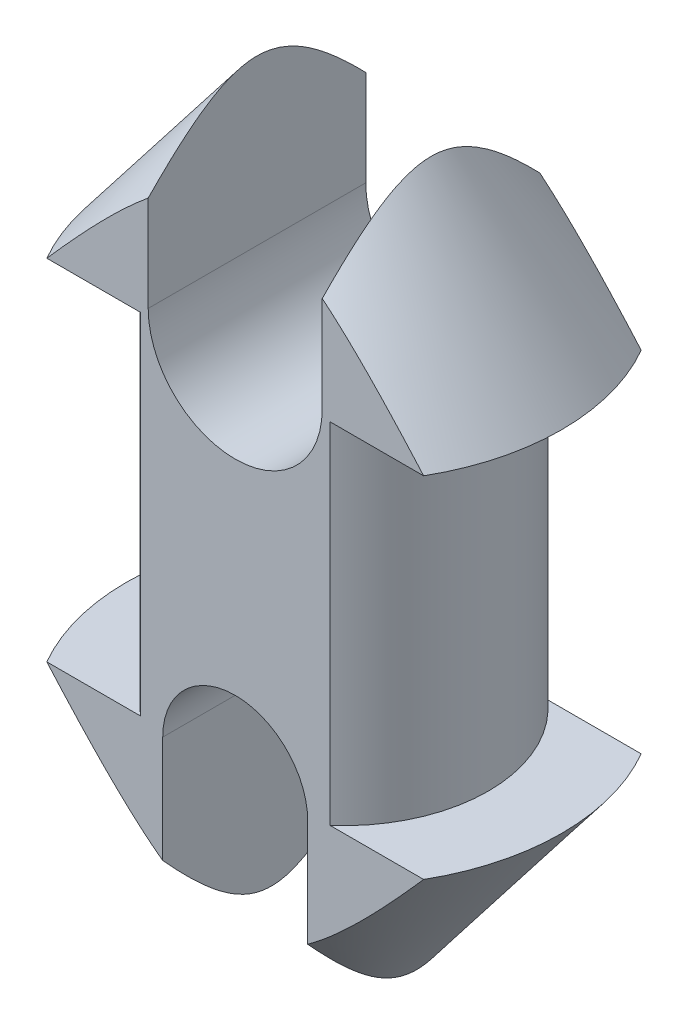
from build123d import *

# Parameters (mm, degrees)
ESBO_O2_OUTSIDE_W          = 45.75
ESBO_O2_OUTSIDE_H          = 45.75
ESBO_O2_OUTSIDE_W_2        = 30
ESBO_O2_OUTSIDE_H_2        = 15
CORTE_EXTRUS_O1_DEPTH      = 28.05
CORTE_EXTRUS_O1_DEPTH_BACK = 28.05
CORTE_EXTRUS_O2_DEPTH      = 16


with BuildPart() as part:
    # Esboço1 one side → Revolução1 (revolve)
    with BuildSketch(Plane.XY):
        with BuildLine():
            ThreePointArc((4, 26.506832295), (2.018355219, 26.913587797), (0, 27.05))
            Line((0, 27.05), (0, -27.05))
            ThreePointArc((0, -27.05), (2.018355219, -26.913587797), (4, -26.506832295))
            Line((4, -26.506832295), (15, -12.05))
            Line((15, -12.05), (9.95, -12.05))
            Line((9.95, -12.05), (9.95, 12.05))
            Line((9.95, 12.05), (15, 12.05))
            Line((15, 12.05), (4, 26.506832295))
        make_face()
    revolve(axis=Axis((0, -27.05, 0), (0, 1, 0)))

    # Esboço2 outside → Corte-extrusão1 (cut, two sides)
    with BuildSketch(Plane(origin=(0, 0, 0), x_dir=(1, 0, 0), z_dir=(0, 1, 0))) as corte_extrus_o1_sk:
        Rectangle(ESBO_O2_OUTSIDE_W, ESBO_O2_OUTSIDE_H)
        Rectangle(ESBO_O2_OUTSIDE_W_2, ESBO_O2_OUTSIDE_H_2, mode=Mode.SUBTRACT)
    extrude(amount=CORTE_EXTRUS_O1_DEPTH, mode=Mode.SUBTRACT)
    extrude(corte_extrus_o1_sk.sketch, amount=-CORTE_EXTRUS_O1_DEPTH_BACK, mode=Mode.SUBTRACT)

    # Esboço3 → Corte-extrusão2 (cut, through all)
    with BuildSketch(Plane(origin=(0, 0, -7.5), x_dir=(-1, 0, 0), z_dir=(0, 0, -1))):
        with BuildLine():
            Line((6, 27.05), (6, 12.55))
            ThreePointArc((6, 12.55), (0, 6.55), (-6, 12.55))
            Line((-6, 12.55), (-6, 27.05))
            ThreePointArc((-6, 27.05), (0, 33.05), (6, 27.05))
        make_face()
        with BuildLine():
            Line((-5, -27.05), (-5, -12.55))
            ThreePointArc((-5, -12.55), (0, -7.55), (5, -12.55))
            Line((5, -12.55), (5, -27.05))
            ThreePointArc((5, -27.05), (0, -32.05), (-5, -27.05))
        make_face()
    extrude(amount=-CORTE_EXTRUS_O2_DEPTH, mode=Mode.SUBTRACT)


solid = part.part
